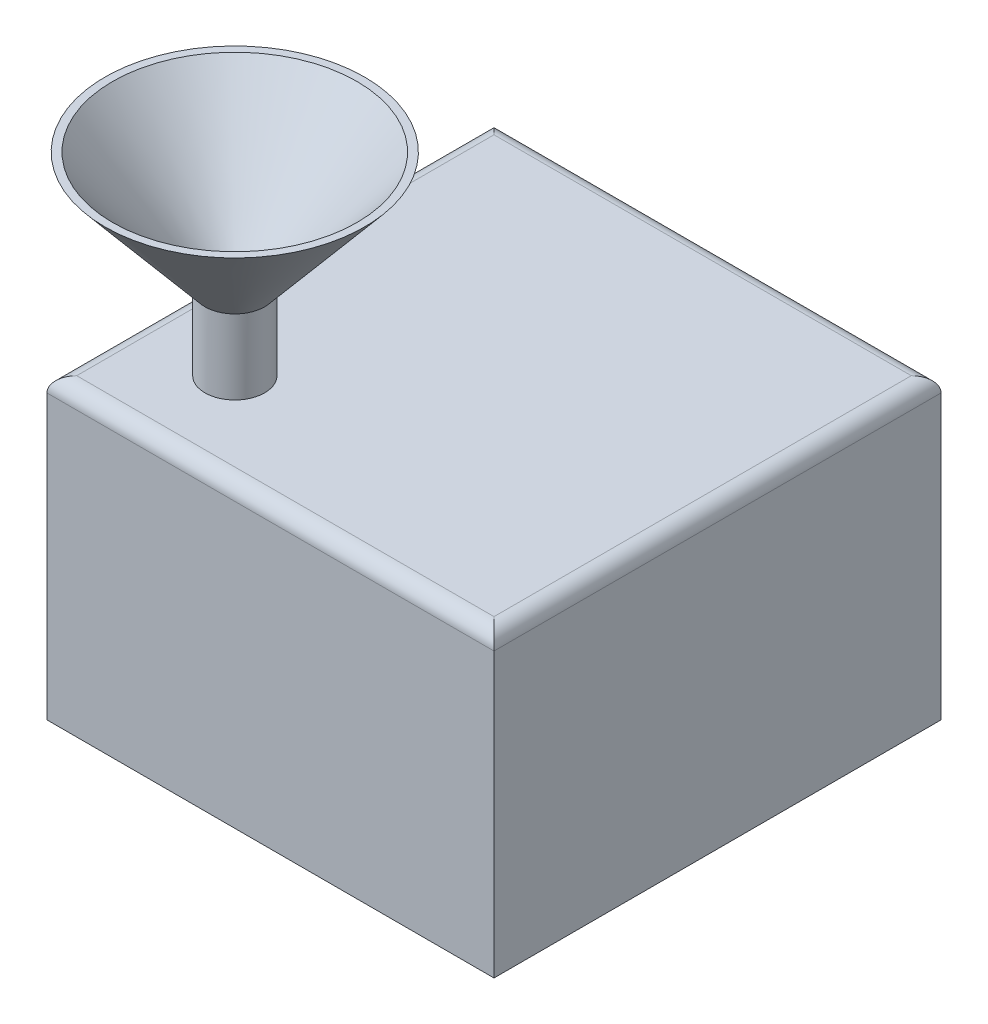
from build123d import *

# Parameters (mm, degrees)
SKETCH1_W           = 300
SKETCH1_H           = 300
BOSS_EXTRUDE1_DEPTH = 200
FILLET1_R           = 10
SKETCH2_R           = 20
SKETCH2_R_2         = 15
BOSS_EXTRUDE2_DEPTH = 50
SKETCH3_R           = 20
BOSS_EXTRUDE3_DEPTH = 80
BOSS_EXTRUDE3_TAPER = -40
SKETCH4_R           = 82
CUT_EXTRUDE1_DEPTH  = 80
CUT_EXTRUDE1_TAPER  = 40


with BuildPart() as part:
    # Sketch1 → Boss-Extrude1 (new body)
    with BuildSketch(Plane(origin=(0, 0, 0), x_dir=(1, 0, 0), z_dir=(0, 1, 0))):
        Rectangle(SKETCH1_W, SKETCH1_H)
    extrude(amount=BOSS_EXTRUDE1_DEPTH)

    # Fillet1
    fillet1_edges = [part.edges().sort_by_distance(p)[0] for p in [
        (-150, 200, 0),
        (0, 200, 150),
        (150, 200, 0),
        (0, 200, -150),
    ]]
    fillet(fillet1_edges, radius=FILLET1_R)

    # Sketch2 → Boss-Extrude2 (add)
    with BuildSketch(Plane(origin=(0, 200, 0), x_dir=(1, 0, 0), z_dir=(0, 1, 0))):
        with Locations((-86.966991411, -86.966991411)):
            Circle(SKETCH2_R)
        with Locations((-86.966991411, -86.966991411)):
            Circle(SKETCH2_R_2, mode=Mode.SUBTRACT)
    extrude(amount=BOSS_EXTRUDE2_DEPTH)

    # Sketch3 → Boss-Extrude3 (add)
    with BuildSketch(Plane(origin=(0, 250, 0), x_dir=(1, 0, 0), z_dir=(0, 1, 0))):
        with Locations((-86.966991411, -86.966991411)):
            Circle(SKETCH3_R)
    extrude(amount=BOSS_EXTRUDE3_DEPTH, taper=BOSS_EXTRUDE3_TAPER)

    # Sketch4 → Cut-Extrude1 (cut)
    with BuildSketch(Plane(origin=(0, 330, 0), x_dir=(1, 0, 0), z_dir=(0, 1, 0))):
        with Locations((-86.966991411, -86.966991411)):
            Circle(SKETCH4_R)
    extrude(amount=-CUT_EXTRUDE1_DEPTH, taper=CUT_EXTRUDE1_TAPER, mode=Mode.SUBTRACT)


solid = part.part
